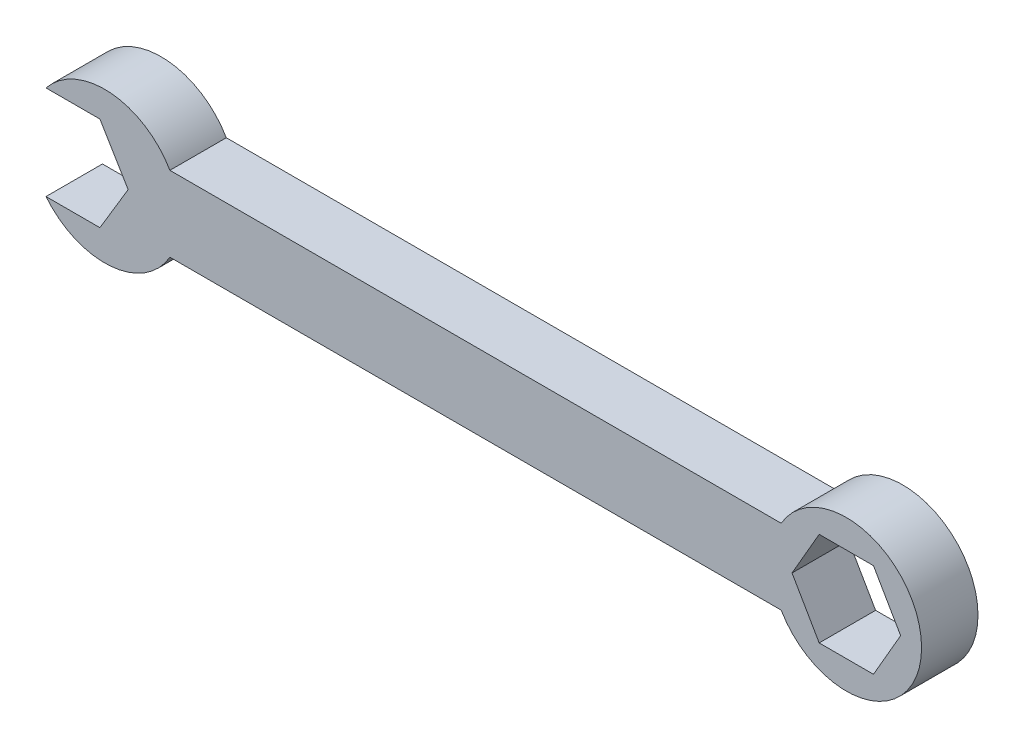
from build123d import *

# Parameters (mm, degrees)
BOSS_EXTRUDE1_DEPTH = 7.62


with BuildPart() as part:
    # Sketch1 → Boss-Extrude1 (new body)
    with BuildSketch(Plane.XY):
        with BuildLine():
            Line((-58.00496556, 6.35), (-50.723882736, 6.35))
            Line((-50.723882736, 6.35), (-46.913882736, 0))
            Line((-46.913882736, 0), (-50.723882736, -6.35))
            Line((-50.723882736, -6.35), (-58.00496556, -6.35))
            ThreePointArc((-58.00496556, -6.35), (-49.304767983, -10.130851984), (-41.275, -5.08))
            Line((-41.275, -5.08), (41.275, -5.08))
            ThreePointArc((41.275, -5.08), (60.233818102, 0), (41.275, 5.08))
            Line((41.275, 5.08), (-41.275, 5.08))
            ThreePointArc((-41.275, 5.08), (-49.304767983, 10.130851984), (-58.00496556, 6.35))
        make_face()
        Polygon((57.406166521, 0), (53.739992312, 6.35), (46.407643893, 6.35), (42.741469684, 0), (46.407643893, -6.35), (53.739992312, -6.35), align=None, mode=Mode.SUBTRACT)
    extrude(amount=BOSS_EXTRUDE1_DEPTH)


solid = part.part
